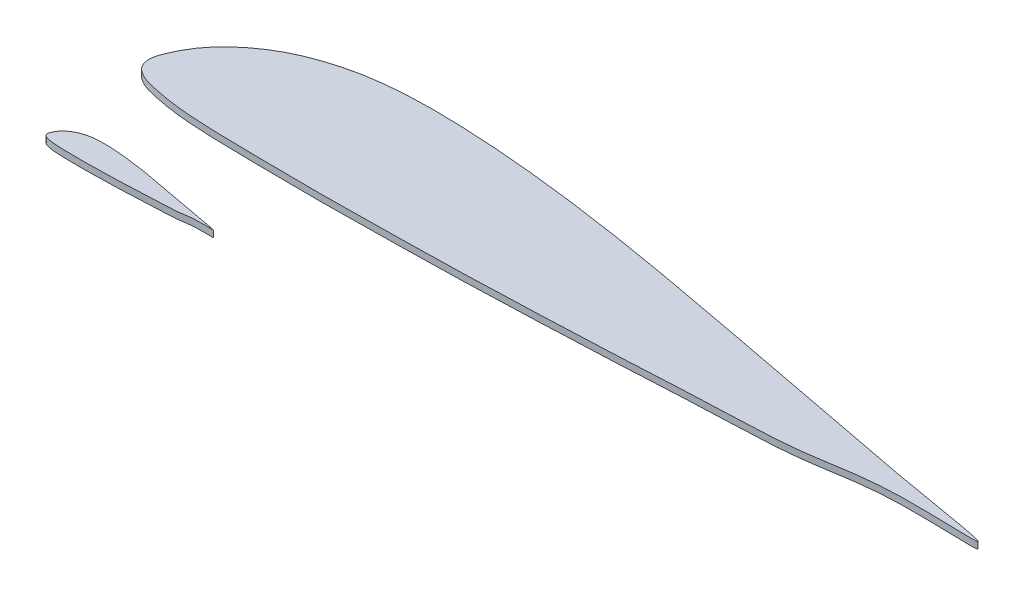
from build123d import *

# Parameters (mm, degrees)
BOSS_EXTRUDE2_DEPTH   = 4
BOSS_EXTRUDE2_2_DEPTH = 4


with BuildPart() as part:
    # Sketch2 → Boss-Extrude2 (new body)
    with BuildSketch(Plane(origin=(0, 0, 0), x_dir=(1, 0, 0), z_dir=(0, 1, 0))):
        with BuildLine():
            add(Edge.make_bspline(
                [(100, 0), (100.062832481, 0.251035491), (88.423782974, 2.077171545), (80.42251087, 3.753346357), (69.886173545, 5.709443028), (60.038664734, 7.607750011), (50.016738031, 9.448794891), (40.032646993, 10.974024804), (31.681442376, 11.857617234), (25.003732925, 12.218802233), (19.991287342, 12.255901671), (14.932026744, 11.831525262), (10.552698907, 10.717194811), (7.226014658, 9.264268293), (4.894142811, 7.740900366), (3.227317175, 6.302068696), (1.907577305, 4.784574924), (1.090513349, 3.517602977), (0.31110434, 1.94974357), (-0.274693213, 0.387957211), (0.322414802, -0.985991259), (1.128085986, -1.553275899), (1.960743073, -1.980402203), (3.325075799, -2.314398918), (4.988474859, -2.651519441), (7.325893482, -2.960829773), (10.662702275, -3.183298157), (14.99974317, -3.252309923), (19.999702383, -3.317990736), (25.000304183, -3.335714915), (31.666611827, -3.233615687), (40.004541812, -3.118802793), (49.993702731, -2.747917107), (60.032071472, -2.329079334), (69.887259845, -1.735293531), (80.450181756, -1.52889579), (88.417460145, 0.540970313), (99.938271834, -0.246623405), (100, 0)],
                knots=[0, 0, 0, 0, 0.049040866, 0.098081731, 0.147122597, 0.196163463, 0.245116686, 0.293834629, 0.342263553, 0.366385573, 0.390475046, 0.414675268, 0.439565651, 0.455415353, 0.466907824, 0.479711554, 0.487090329, 0.495936907, 0.501323477, 0.512663454, 0.51831006, 0.521365152, 0.526751722, 0.531754914, 0.54158153, 0.551304728, 0.565797224, 0.589894838, 0.613986045, 0.638075566, 0.662166773, 0.710353523, 0.758560308, 0.806785868, 0.855025, 0.903284915, 0.951821054, 1, 1, 1, 1], degree=3))
        make_face()
    extrude(amount=BOSS_EXTRUDE2_DEPTH)


with BuildPart() as body_2:
    # Sketch2 → Boss-Extrude2 2 (new body)
    with BuildSketch(Plane(origin=(0, 0, 0), x_dir=(1, 0, 0), z_dir=(0, 1, 0))):
        with BuildLine():
            add(Edge.make_bspline(
                [(492, 67.652117248), (492.314162405, 68.907294703), (434.118914869, 78.037974972), (394.112554351, 86.418849032), (341.430867726, 96.199332388), (292.193323672, 105.690867304), (242.083690154, 114.896091705), (192.163234967, 122.522241268), (150.407211882, 126.940203416), (117.018664623, 128.746128415), (91.956436712, 128.931625601), (66.660133722, 126.809743559), (44.763494535, 121.238091304), (28.13007329, 113.973458713), (16.470714055, 106.356619079), (8.136585877, 99.162460728), (1.537886524, 91.574991866), (-2.547433257, 85.240132134), (-6.444478298, 77.400835097), (-9.373466064, 69.591903304), (-6.387925991, 62.722160951), (-2.359570071, 59.885737754), (1.803715363, 57.750106235), (8.625378995, 56.080122656), (16.942374293, 54.394520041), (28.629467411, 52.847968384), (45.313511377, 51.735626463), (66.998715848, 51.390567635), (91.998511917, 51.062163568), (117.001520917, 50.973542674), (150.333059135, 51.484038815), (192.022709059, 52.058103286), (241.968513653, 53.912531711), (292.160357362, 56.006720578), (341.436299225, 58.975649591), (394.250908778, 60.007638299), (434.087300725, 70.356968815), (491.691359172, 66.419000226), (492, 67.652117248)],
                knots=[0, 0, 0, 0, 0.049040866, 0.098081731, 0.147122597, 0.196163463, 0.245116686, 0.293834629, 0.342263553, 0.366385573, 0.390475046, 0.414675268, 0.439565651, 0.455415353, 0.466907824, 0.479711554, 0.487090329, 0.495936907, 0.501323477, 0.512663454, 0.51831006, 0.521365152, 0.526751722, 0.531754914, 0.54158153, 0.551304728, 0.565797224, 0.589894838, 0.613986045, 0.638075566, 0.662166773, 0.710353523, 0.758560308, 0.806785868, 0.855025, 0.903284915, 0.951821054, 1, 1, 1, 1], degree=3))
        make_face()
    extrude(amount=BOSS_EXTRUDE2_2_DEPTH)


solid = Compound([part.part, body_2.part])
